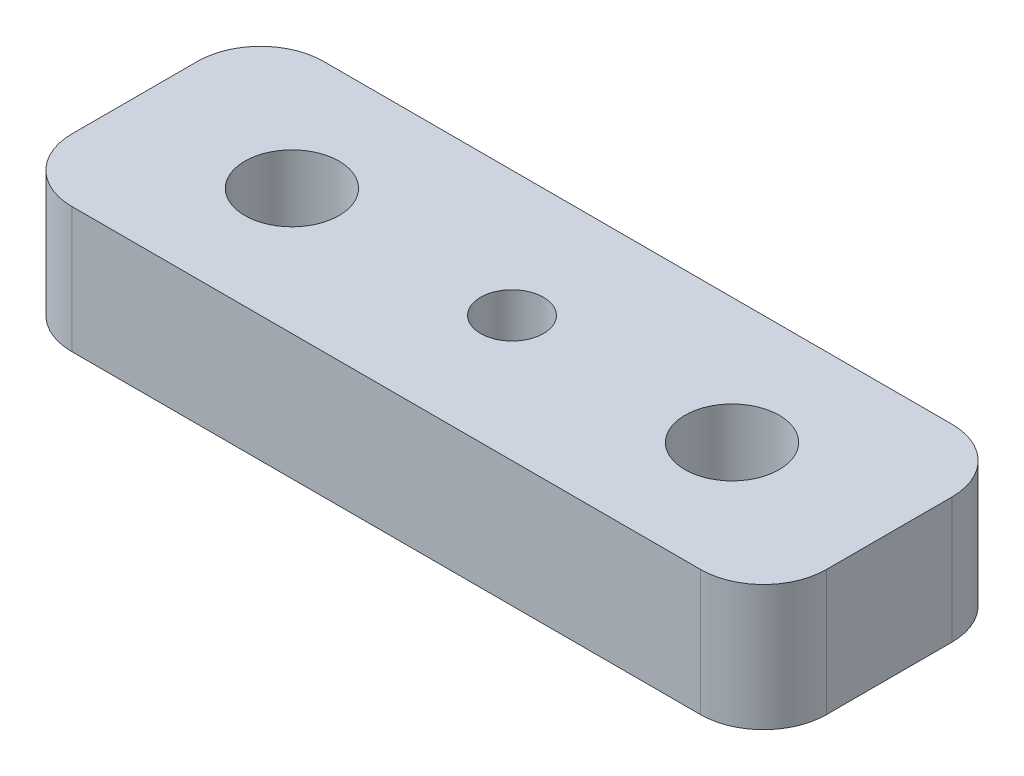
from build123d import *

# Parameters (mm, degrees)
BOSS_EXTRUDE1_DEPTH = 4
CUT_EXTRUDE1_REACH  = 15.266
SKETCH1_3_R         = 1
SKETCH1_3_R_2       = 1.5
SKETCH1_4_R         = 2.5
CUT_EXTRUDE2_DEPTH  = 2


with BuildPart() as part:
    # Sketch1 → Boss-Extrude1 (new body)
    with BuildSketch(Plane(origin=(0, 0, 0), x_dir=(1, 0, 0), z_dir=(0, 1, 0))):
        with BuildLine():
            Line((0, 4), (10, 4))
            ThreePointArc((10, 4), (11.414213562, 3.414213562), (12, 2))
            Line((12, 2), (12, -2))
            ThreePointArc((12, -2), (11.414213562, -3.414213562), (10, -4))
            Line((10, -4), (0, -4))
            Line((0, -4), (-10, -4))
            ThreePointArc((-10, -4), (-11.414213562, -3.414213562), (-12, -2))
            Line((-12, -2), (-12, 2))
            ThreePointArc((-12, 2), (-11.414213562, 3.414213562), (-10, 4))
            Line((-10, 4), (0, 4))
        make_face()
    extrude(amount=BOSS_EXTRUDE1_DEPTH)

    # Sketch1_3 → Cut-Extrude1 (cut, up to next)
    with BuildSketch(Plane(origin=(0, 0, 0), x_dir=(1, 0, 0), z_dir=(0, 1, 0)), mode=Mode.PRIVATE) as cut_extrude1_sk1:
        Circle(SKETCH1_3_R)
    cut_extrude1_tool1 = extrude(cut_extrude1_sk1.sketch, amount=CUT_EXTRUDE1_REACH, mode=Mode.PRIVATE) & part.part
    # Sketch1_3 → Cut-Extrude1 (cut, up to next)
    with BuildSketch(Plane(origin=(0, 0, 0), x_dir=(1, 0, 0), z_dir=(0, 1, 0)), mode=Mode.PRIVATE) as cut_extrude1_sk2:
        with Locations((-7, 0)):
            Circle(SKETCH1_3_R_2)
    cut_extrude1_tool2 = extrude(cut_extrude1_sk2.sketch, amount=CUT_EXTRUDE1_REACH, mode=Mode.PRIVATE) & part.part
    # Sketch1_3 → Cut-Extrude1 (cut, up to next)
    with BuildSketch(Plane(origin=(0, 0, 0), x_dir=(1, 0, 0), z_dir=(0, 1, 0)), mode=Mode.PRIVATE) as cut_extrude1_sk3:
        with Locations((7, 0)):
            Circle(SKETCH1_3_R_2)
    cut_extrude1_tool3 = extrude(cut_extrude1_sk3.sketch, amount=CUT_EXTRUDE1_REACH, mode=Mode.PRIVATE) & part.part
    add(cut_extrude1_tool1.solids().sort_by_distance((0, 0, 0))[0], mode=Mode.SUBTRACT)
    add(cut_extrude1_tool2.solids().sort_by_distance((-7, 0, 0))[0], mode=Mode.SUBTRACT)
    add(cut_extrude1_tool3.solids().sort_by_distance((7, 0, 0))[0], mode=Mode.SUBTRACT)

    # Sketch1_4 → Cut-Extrude2 (cut)
    with BuildSketch(Plane(origin=(0, 0, 0), x_dir=(1, 0, 0), z_dir=(0, 1, 0))):
        Circle(SKETCH1_4_R)
    extrude(amount=CUT_EXTRUDE2_DEPTH, mode=Mode.SUBTRACT)


solid = part.part
